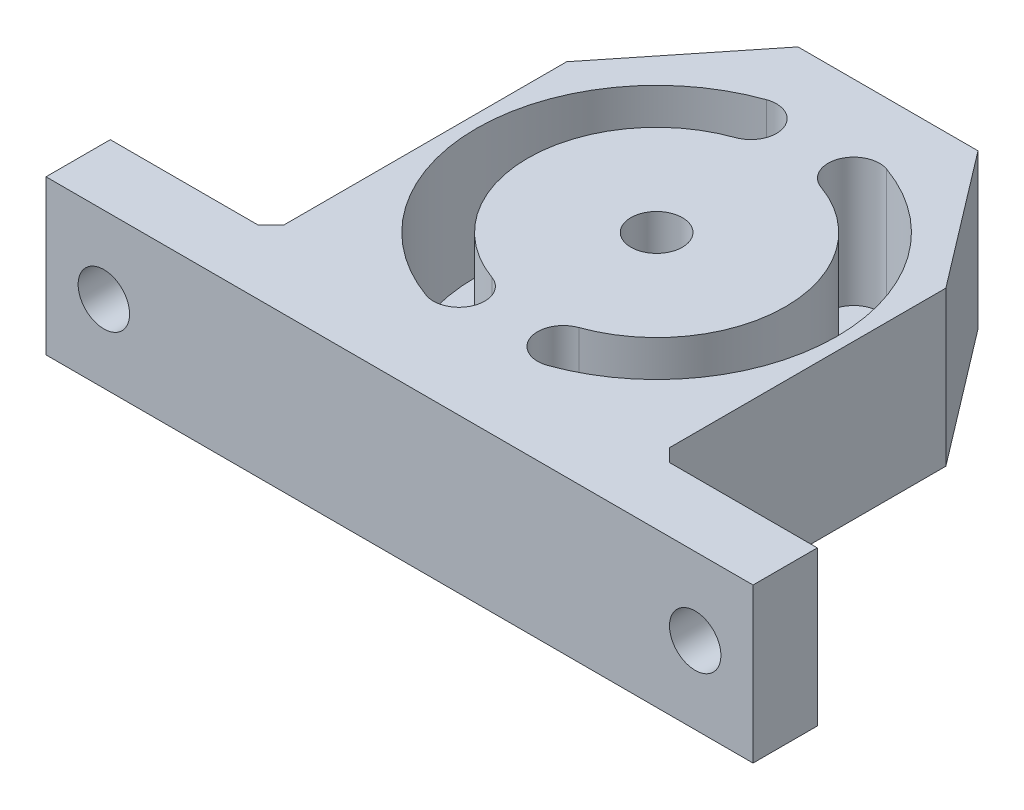
from build123d import *

# Parameters (mm, degrees)
BOSS_EXTRUDE1_DEPTH = 12
SKETCH2_R           = 2
CUT_EXTRUDE1_DEPTH  = 49.41745553
CUT_EXTRUDE2_DEPTH  = 10
CUT_EXTRUDE3_DEPTH  = 37.912057651
CHAMFER1_SIZE       = 1


with BuildPart() as part:
    # Sketch1 → Boss-Extrude1 (new body)
    with BuildSketch(Plane(origin=(0, 0, 0), x_dir=(1, 0, 0), z_dir=(0, 1, 0))):
        Polygon((15, -16.5), (27.5, -16.5), (27.5, -21.5), (-27.5, -21.5), (-27.5, -16.5), (-15, -16.5), (-15, 6.5), (-7, 16.5), (7, 16.5), (15, 6), align=None)
    extrude(amount=BOSS_EXTRUDE1_DEPTH)

    # Sketch2 → Cut-Extrude1 (cut, through all)
    with BuildSketch(Plane.XY.offset(21.5)):
        with Locations((-23, 6)):
            Circle(SKETCH2_R)
        with Locations((23, 6)):
            Circle(SKETCH2_R)
    extrude(amount=-CUT_EXTRUDE1_DEPTH, mode=Mode.SUBTRACT)

    # Sketch3 → Cut-Extrude2 (cut)
    with BuildSketch(Plane(origin=(0, 12, 0), x_dir=(1, 0, 0), z_dir=(0, 1, 0))):
        with BuildLine():
            ThreePointArc((-3.339472326, 7.945454111), (-2.12052091, 10.49773886), (-4.67280566, 11.716690277))
            ThreePointArc((-4.67280566, 11.716690277), (-14.018384458, -1.469804084), (-4.729700131, -14.696437068))
            ThreePointArc((-4.729700131, -14.696437068), (-2.172187792, -13.488492269), (-3.380132591, -10.93097993))
            ThreePointArc((-3.380132591, -10.93097993), (-10.018393738, -1.478420154), (-3.339472326, 7.945454111))
        make_face()
        with BuildLine():
            ThreePointArc((4.729700131, -14.696437068), (14.018384458, -1.469804084), (4.67280566, 11.716690277))
            ThreePointArc((4.67280566, 11.716690277), (2.12052091, 10.49773886), (3.339472326, 7.945454111))
            ThreePointArc((3.339472326, 7.945454111), (10.018393738, -1.478420154), (3.380132591, -10.93097993))
            ThreePointArc((3.380132591, -10.93097993), (2.172187792, -13.488492269), (4.729700131, -14.696437068))
        make_face()
    extrude(amount=-CUT_EXTRUDE2_DEPTH, mode=Mode.SUBTRACT)

    # Sketch3_7 → Cut-Extrude3 (cut, through all)
    with BuildSketch(Plane(origin=(0, 12, 0), x_dir=(1, 0, 0), z_dir=(0, 1, 0))):
        with BuildLine():
            ThreePointArc((0, 0.5), (-1.414213562, -2.914213562), (2, -1.5))
            ThreePointArc((2, -1.5), (1.414213562, -0.085786438), (0, 0.5))
        make_face()
    extrude(amount=-CUT_EXTRUDE3_DEPTH, mode=Mode.SUBTRACT)

    # Chamfer1
    chamfer1_edges = [part.edges().sort_by_distance(p)[0] for p in [
        (-15, 6, 16.5),
        (15, 6, 16.5),
    ]]
    chamfer(chamfer1_edges, length=CHAMFER1_SIZE)


solid = part.part
